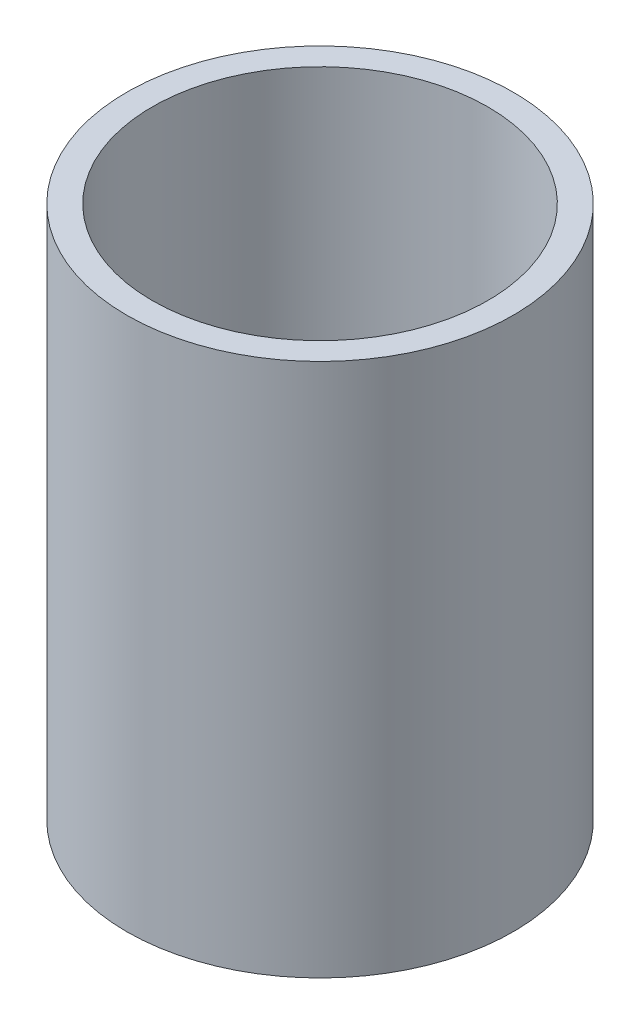
from build123d import *

# Parameters (mm, degrees)
SKETCH1_W = 6.35
SKETCH1_H = 133.35


with BuildPart() as part:
    # Sketch1 → Revolve1 (revolve)
    with BuildSketch(Plane.XY):
        with Locations((-45.085, -21.057365567)):
            Rectangle(SKETCH1_W, SKETCH1_H)
    revolve(axis=Axis((0, 55, 0), (0, -1, 0)))


solid = part.part
